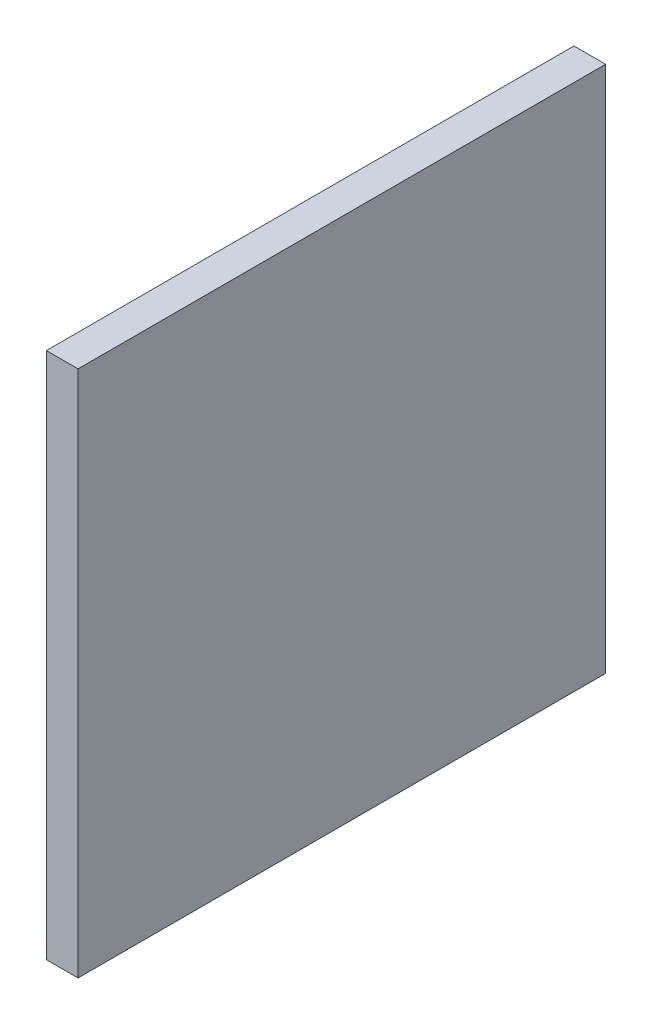
from build123d import *

# Parameters (mm, degrees)
ESQUISSE2_W        = 50
ESQUISSE2_H        = 50
BOSS_EXTRU_1_DEPTH = 3


with BuildPart() as part:
    # Esquisse2 → Boss.-Extru.1 (new body)
    with BuildSketch(Plane(origin=(0, 0, 0), x_dir=(0, 0, -1), z_dir=(1, 0, 0))):
        with Locations((-54.181765908, -11.726235788)):
            Rectangle(ESQUISSE2_W, ESQUISSE2_H)
    extrude(amount=BOSS_EXTRU_1_DEPTH)


solid = part.part
